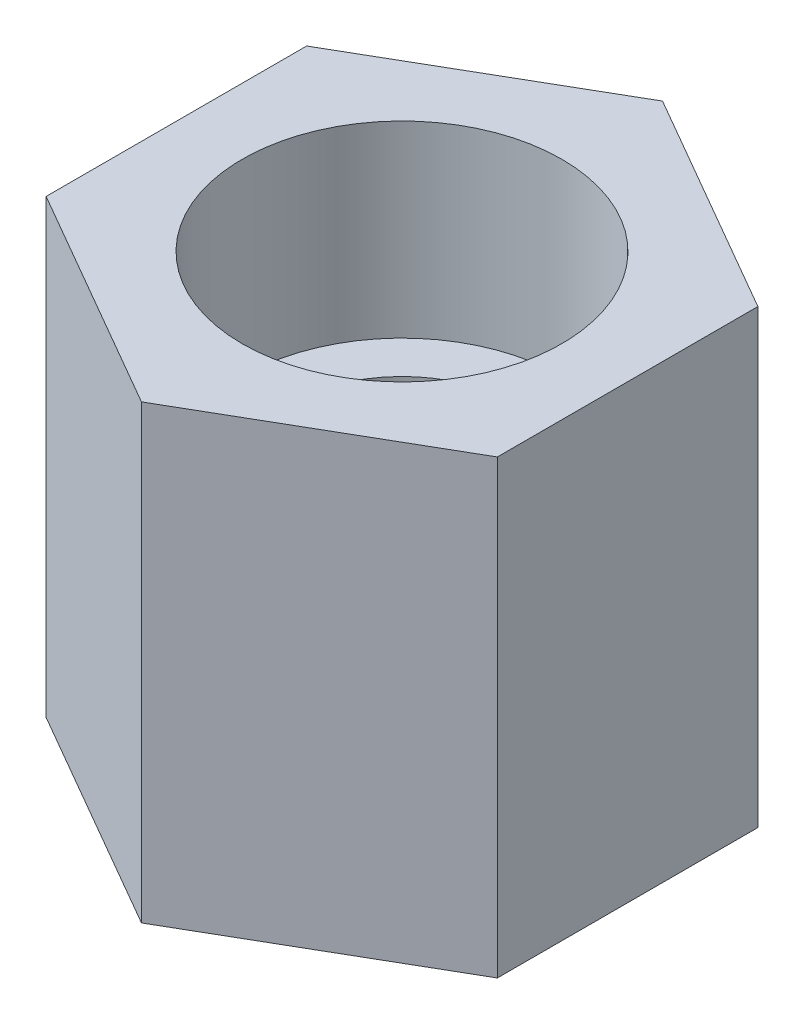
from build123d import *

# Parameters (mm, degrees)
SKETCH_1_R          = 6
EXTRUDE_1_DEPTH     = 24
SKETCH_3_R          = 8.5
CUT_EXTRUDE_2_DEPTH = 10


with BuildPart() as part:
    # Эскиз1 → Бобышка-Вытянуть1 (new body)
    with BuildSketch(Plane(origin=(0, 0, 0), x_dir=(1, 0, 0), z_dir=(0, 1, 0))):
        Polygon((0, 13.856406461), (-12, 6.92820323), (-12, -6.92820323), (0, -13.856406461), (12, -6.92820323), (12, 6.92820323), align=None)
        Circle(SKETCH_1_R, mode=Mode.SUBTRACT)
    extrude(amount=EXTRUDE_1_DEPTH)

    # Эскиз3 → Вырез-Вытянуть2 (cut)
    with BuildSketch(Plane(origin=(0, 24, 0), x_dir=(1, 0, 0), z_dir=(0, 1, 0))):
        Circle(SKETCH_3_R)
    extrude(amount=-CUT_EXTRUDE_2_DEPTH, mode=Mode.SUBTRACT)


solid = part.part
